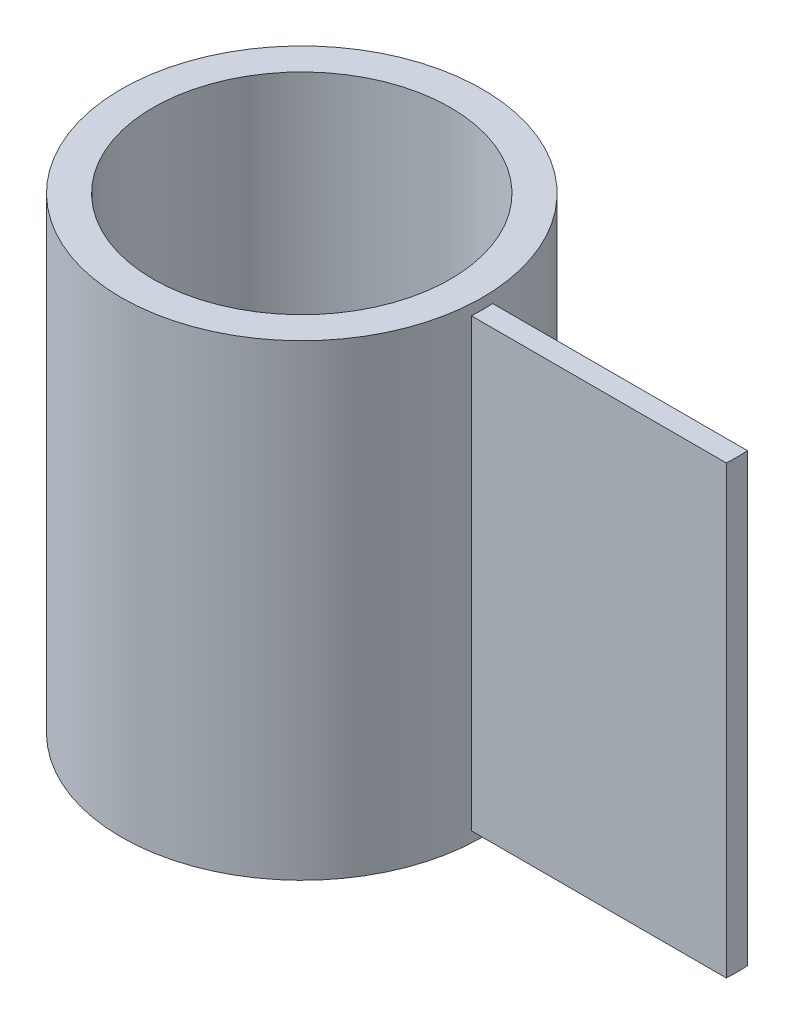
from build123d import *

# Parameters (mm, degrees)
SKETCH1_R                  = 42.5
SKETCH1_R_2                = 35
BOSS_EXTRUDE1_DEPTH        = 110
BOSS_EXTRUDE2_REACH        = 187.35
BOSS_EXTRUDE2_START_RADIUS = 42.5
BOSS_EXTRUDE2_END_RADIUS   = 42.5
SKETCH2_W                  = 5
SKETCH2_H                  = 105


with BuildPart() as part:
    # Sketch1 → Boss-Extrude1 (new body)
    with BuildSketch(Plane(origin=(0, 0, 0), x_dir=(1, 0, 0), z_dir=(0, 1, 0))):
        with Locations(Location((0, 0, 0), (0, 0, 270))):
            Circle(SKETCH1_R)
        with Locations(Location((0, 0, 0), (0, 0, 270))):
            Circle(SKETCH1_R_2, mode=Mode.SUBTRACT)
    extrude(amount=BOSS_EXTRUDE1_DEPTH)

    # Boss-Extrude2: from a cylinder face, 187.35 long prism both ways, kept between that surface and its translate by the depth
    boss_extrude2_start = Plane(origin=(0, 55, 0), z_dir=(0, -1, 0)) * Cylinder(BOSS_EXTRUDE2_START_RADIUS, 460.7, mode=Mode.PRIVATE)
    boss_extrude2_end = Plane(origin=(60, 55, 0), z_dir=(0, -1, 0)) * Cylinder(BOSS_EXTRUDE2_END_RADIUS, 460.7, mode=Mode.PRIVATE)
    # Sketch2 → Boss-Extrude2 (add, from a surface)
    with BuildSketch(Plane(origin=(0, 0, 0), x_dir=(0, 0, -1), z_dir=(1, 0, 0)), mode=Mode.PRIVATE) as boss_extrude2_sk1:
        with Locations((0, 55)):
            Rectangle(SKETCH2_W, SKETCH2_H)
    boss_extrude2_tool1 = extrude(boss_extrude2_sk1.sketch, amount=BOSS_EXTRUDE2_REACH, both=True, mode=Mode.PRIVATE)
    add(((boss_extrude2_tool1 - boss_extrude2_start) & boss_extrude2_end).solids().sort_by_distance((72.426407, 55, 0))[0])


solid = part.part
